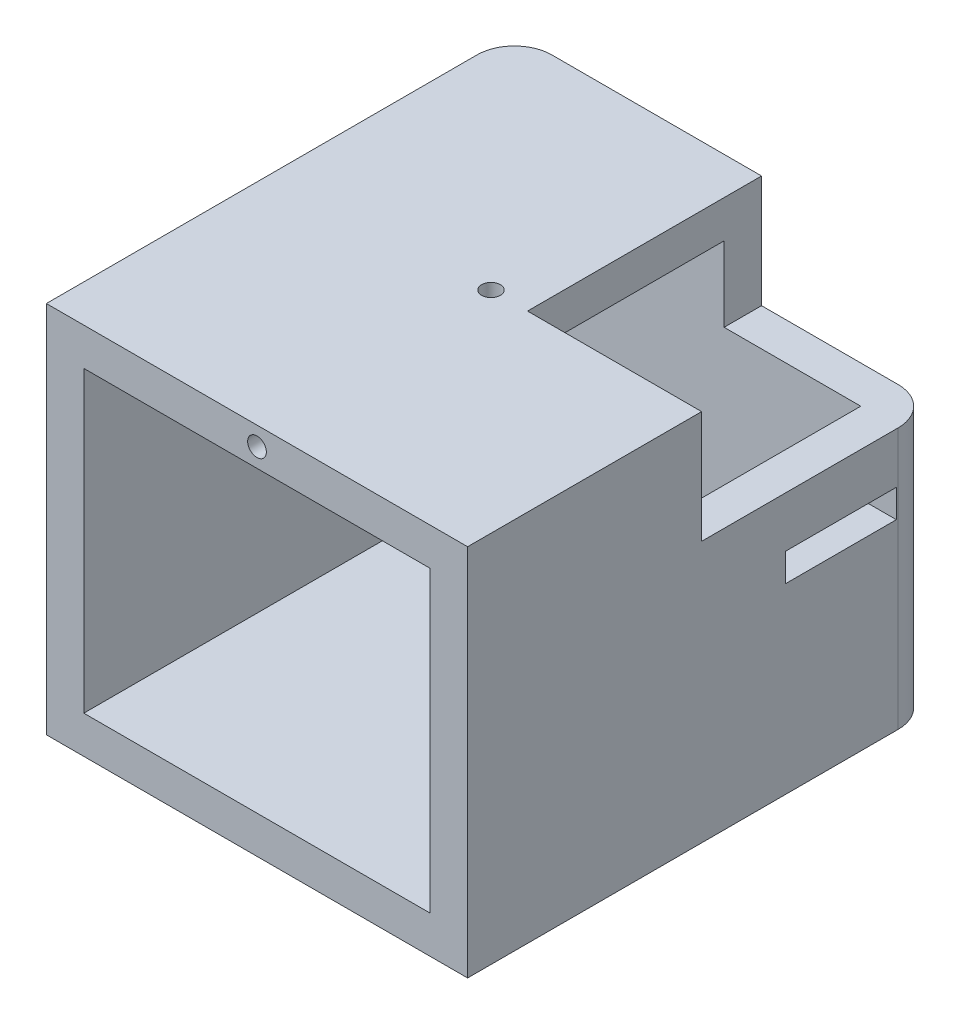
from build123d import *

# Parameters (mm, degrees)
CROQUIS1_W                        = 50
CROQUIS1_H                        = 39.9
SALIENTE_EXTRUIR1_DEPTH           = 22.5
VACIADO1_T                        = -4
CORTAR_EXTRUIR1_START             = -9.2
CORTAR_EXTRUIR1_DEPTH             = 3.5
CORTAR_EXTRUIR3_REACH             = 41.9
CROQUIS4_R                        = 1
CORTAR_EXTRUIR3_DIRECTION_2_DEPTH = 1
CROQUIS5_R                        = 1
CORTAR_EXTRUIR4_DEPTH             = 5
CORTAR_EXTRUIR5_DEPTH             = 12
CROQUIS8_W                        = 11.85
CROQUIS8_H                        = 3
CORTAR_EXTRUIR6_DEPTH             = 1
CORTAR_EXTRUIR6_DEPTH_BACK        = 46
REDONDEO1_R                       = 4


with BuildPart() as part:
    # Croquis1 → Saliente-Extruir1 (new body, symmetric)
    with BuildSketch(Plane(origin=(0, 0, 0), x_dir=(0, 0, -1), z_dir=(1, 0, 0))):
        Rectangle(CROQUIS1_W, CROQUIS1_H)
    extrude(amount=SALIENTE_EXTRUIR1_DEPTH, both=True)

    # Vaciado1
    vaciado1_openings = [part.faces().sort_by_distance(p)[0] for p in [
        (0, 0, 25),
    ]]
    offset(amount=VACIADO1_T, openings=vaciado1_openings, kind=Kind.INTERSECTION)

    # Croquis2 → Cortar-Extruir1 (cut)
    with BuildSketch(Plane(origin=(0, 19.95, 0), x_dir=(1, 0, 0), z_dir=(0, 1, 0)).offset(CORTAR_EXTRUIR1_START)):
        Polygon((-22.5, 25), (-5.9, 25), (-5.9, 21), (-18.5, 21), (-18.5, 0), (-22.5, 0), align=None)
        Polygon((18.5, 0), (22.5, 0), (22.5, 25), (5.9, 25), (5.9, 21), (18.5, 21), align=None)
    extrude(amount=CORTAR_EXTRUIR1_DEPTH, mode=Mode.SUBTRACT)

    # Croquis4 → Cortar-Extruir3 (cut, up to next)
    with BuildSketch(Plane(origin=(0, 19.95, 0), x_dir=(1, 0, 0), z_dir=(0, 1, 0)), mode=Mode.PRIVATE) as cortar_extruir3_sk1:
        Circle(CROQUIS4_R)
    cortar_extruir3_tool1 = extrude(cortar_extruir3_sk1.sketch, amount=-CORTAR_EXTRUIR3_REACH, mode=Mode.PRIVATE) & part.part
    add(cortar_extruir3_tool1.solids().sort_by_distance((0, 19.95, 0))[0], mode=Mode.SUBTRACT)

    # Croquis4 → Cortar-Extruir3 direction 2 (cut)
    with BuildSketch(Plane(origin=(0, 19.95, 0), x_dir=(1, 0, 0), z_dir=(0, 1, 0))):
        Circle(CROQUIS4_R)
    extrude(amount=CORTAR_EXTRUIR3_DIRECTION_2_DEPTH, mode=Mode.SUBTRACT)

    # Croquis5 → Cortar-Extruir4 (cut)
    with BuildSketch(Plane.XY.offset(25)):
        with Locations((0, 17.95)):
            Circle(CROQUIS5_R)
    extrude(amount=-CORTAR_EXTRUIR4_DEPTH, mode=Mode.SUBTRACT)

    # Croquis7 → Cortar-Extruir5 (cut)
    with BuildSketch(Plane(origin=(0, 19.95, 0), x_dir=(1, 0, 0), z_dir=(0, 1, 0))):
        Polygon((5.9, 0), (18.5, 0), (22.5, 0), (22.5, 25), (5.9, 25), (3.9, 25), (3.9, 0), align=None)
    extrude(amount=-CORTAR_EXTRUIR5_DEPTH, mode=Mode.SUBTRACT)

    # Croquis8 → Cortar-Extruir6 (cut, two sides)
    with BuildSketch(Plane.ZY.offset(22.5)) as cortar_extruir6_sk:
        with Locations((-14.875, 1.05)):
            Rectangle(CROQUIS8_W, CROQUIS8_H)
    extrude(amount=CORTAR_EXTRUIR6_DEPTH, mode=Mode.SUBTRACT)
    extrude(cortar_extruir6_sk.sketch, amount=-CORTAR_EXTRUIR6_DEPTH_BACK, mode=Mode.SUBTRACT)

    # Redondeo1
    redondeo1_edges = [part.edges().sort_by_distance(p)[0] for p in [
        (-22.5, 17.1, -25),
        (22.5, -6, -25),
        (-22.5, -4.6, -25),
    ]]
    fillet(redondeo1_edges, radius=REDONDEO1_R)


solid = part.part
